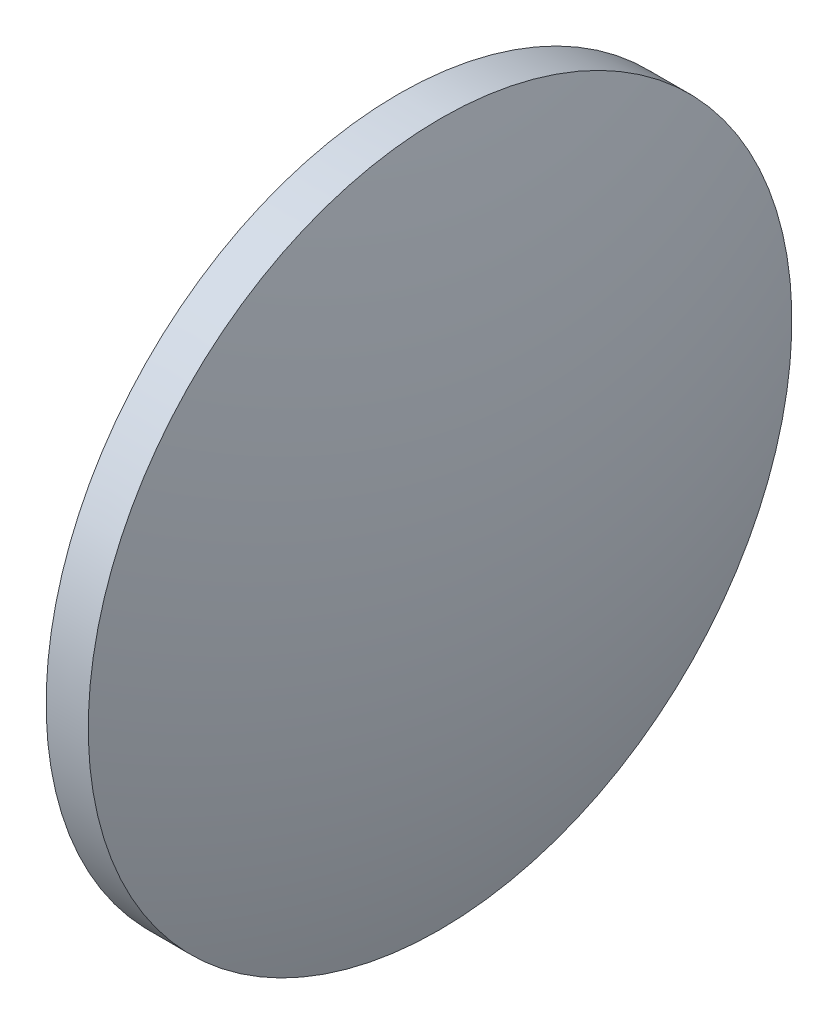
from build123d import *


with BuildPart() as part:
    # 草图1 → 旋转1 (revolve)
    with BuildSketch(Plane.XY, mode=Mode.PRIVATE) as revolve_1_sk:
        with BuildLine():
            Line((453.59766248, -36.1591926), (453.59766248, -11.1591926))
            Line((453.59766248, -11.1591926), (456.59766248, -11.1591926))
            ThreePointArc((456.59766248, -11.1591926), (459.495455293, -23.516904053), (460.467661403, -36.172537218))
            Line((460.467661403, -36.172537218), (453.59766248, -36.1591926))
        make_face()
    revolve(revolve_1_sk.sketch.rotate(Axis((448.949815428, -36.150164398, 0), (0.999998113, -0.001942445, 0)), 180), axis=Axis((448.949815428, -36.150164398, 0), (0.999998113, -0.001942445, 0)))  # turned: the seam where the file's is


solid = part.part
